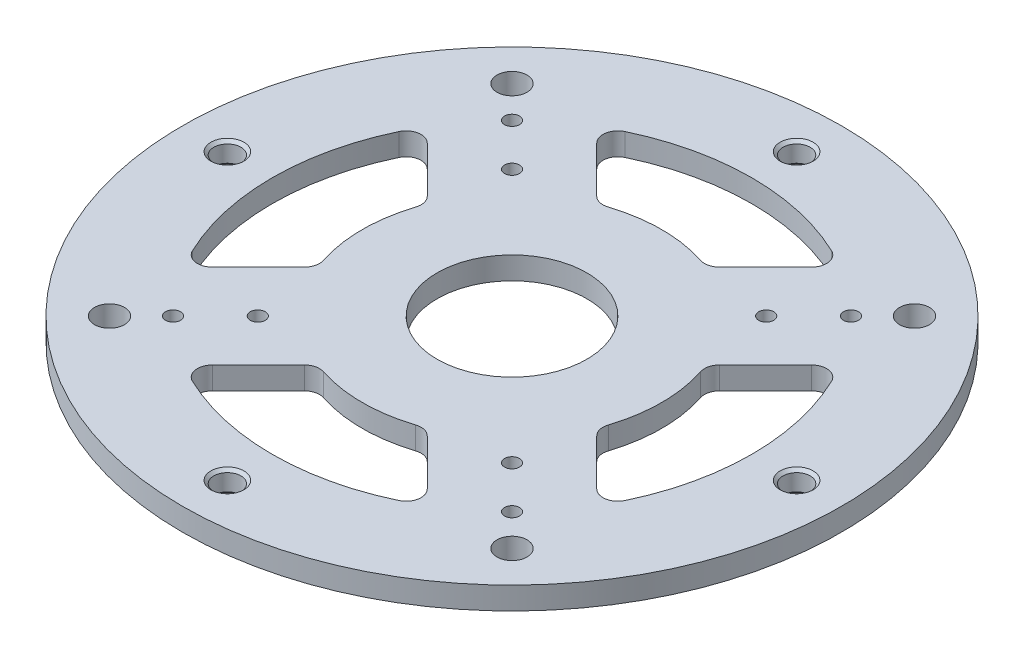
from build123d import *

# Parameters (mm, degrees)
SKETCH2_R                        = 139.7
SKETCH2_R_2                      = 31.75
BOSS_EXTRUDE1_DEPTH              = 9.525
SKETCH3_R                        = 3.175
SKETCH3_R_2                      = 6.35
CUT_EXTRUDE2_DEPTH               = 10.525
F_1_2_20_TAPPED_HOLE1_AT_2_COUNT = 2
F_1_2_20_TAPPED_HOLE1_AT_2_PITCH = 170.6248663
F_1_2_20_TAPPED_HOLE1_AT_3_COUNT = 2
F_1_2_20_TAPPED_HOLE1_AT_3_PITCH = 241.3
F_1_2_20_TAPPED_HOLE1_AT_4_COUNT = 2
F_1_2_20_TAPPED_HOLE1_AT_4_PITCH = 170.6248663


with BuildPart() as part:
    # Sketch2 → Boss-Extrude1 (new body)
    with BuildSketch(Plane(origin=(0, 0, 0), x_dir=(1, 0, 0), z_dir=(0, 1, 0))):
        Circle(SKETCH2_R)
        Circle(SKETCH2_R_2, mode=Mode.SUBTRACT)
        with BuildLine():
            Line((61.954602754, 26.03357827), (81.460512242, 45.539487758))
            ThreePointArc((81.460512242, 45.539487758), (87.024437868, 47.307910551), (91.68068299, 43.785983677))
            ThreePointArc((91.68068299, 43.785983677), (101.6, 0), (91.68068299, -43.785983677))
            ThreePointArc((91.68068299, -43.785983677), (87.024437868, -47.307910551), (81.460512242, -45.539487758))
            Line((81.460512242, -45.539487758), (61.954602754, -26.03357827))
            ThreePointArc((61.954602754, -26.03357827), (60.270643836, -23.027751383), (60.404300741, -19.584954736))
            ThreePointArc((60.404300741, -19.584954736), (63.5, 0), (60.404300741, 19.584954736))
            ThreePointArc((60.404300741, 19.584954736), (60.270643836, 23.027751383), (61.954602754, 26.03357827))
        make_face(mode=Mode.SUBTRACT)
        with BuildLine():
            Line((26.03357827, 61.954602754), (45.539487758, 81.460512242))
            ThreePointArc((45.539487758, 81.460512242), (47.307910551, 87.024437868), (43.785983677, 91.68068299))
            ThreePointArc((43.785983677, 91.68068299), (0, 101.6), (-43.785983677, 91.68068299))
            ThreePointArc((-43.785983677, 91.68068299), (-47.307910551, 87.024437868), (-45.539487758, 81.460512242))
            Line((-45.539487758, 81.460512242), (-26.03357827, 61.954602754))
            ThreePointArc((-26.03357827, 61.954602754), (-23.027751383, 60.270643836), (-19.584954736, 60.404300741))
            ThreePointArc((-19.584954736, 60.404300741), (0, 63.5), (19.584954736, 60.404300741))
            ThreePointArc((19.584954736, 60.404300741), (23.027751383, 60.270643836), (26.03357827, 61.954602754))
        make_face(mode=Mode.SUBTRACT)
        with BuildLine():
            Line((26.03357827, -61.954602754), (45.539487758, -81.460512242))
            ThreePointArc((45.539487758, -81.460512242), (47.307910551, -87.024437868), (43.785983677, -91.68068299))
            ThreePointArc((43.785983677, -91.68068299), (0, -101.6), (-43.785983677, -91.68068299))
            ThreePointArc((-43.785983677, -91.68068299), (-47.307910551, -87.024437868), (-45.539487758, -81.460512242))
            Line((-45.539487758, -81.460512242), (-26.03357827, -61.954602754))
            ThreePointArc((-26.03357827, -61.954602754), (-23.027751383, -60.270643836), (-19.584954736, -60.404300741))
            ThreePointArc((-19.584954736, -60.404300741), (0, -63.5), (19.584954736, -60.404300741))
            ThreePointArc((19.584954736, -60.404300741), (23.027751383, -60.270643836), (26.03357827, -61.954602754))
        make_face(mode=Mode.SUBTRACT)
        with BuildLine():
            Line((-61.954602754, -26.03357827), (-81.460512242, -45.539487758))
            ThreePointArc((-81.460512242, -45.539487758), (-87.024437868, -47.307910551), (-91.68068299, -43.785983677))
            ThreePointArc((-91.68068299, -43.785983677), (-101.6, 0), (-91.68068299, 43.785983677))
            ThreePointArc((-91.68068299, 43.785983677), (-87.024437868, 47.307910551), (-81.460512242, 45.539487758))
            Line((-81.460512242, 45.539487758), (-61.954602754, 26.03357827))
            ThreePointArc((-61.954602754, 26.03357827), (-60.270643836, 23.027751383), (-60.404300741, 19.584954736))
            ThreePointArc((-60.404300741, 19.584954736), (-63.5, 0), (-60.404300741, -19.584954736))
            ThreePointArc((-60.404300741, -19.584954736), (-60.270643836, -23.027751383), (-61.954602754, -26.03357827))
        make_face(mode=Mode.SUBTRACT)
    extrude(amount=BOSS_EXTRUDE1_DEPTH)

    # Sketch3 → Cut-Extrude2 (cut, through all)
    with BuildSketch(Plane(origin=(0, 9.525, 0), x_dir=(1, 0, 0), z_dir=(0, 1, 0))):
        with Locations((-71.842048969, 71.842048969)):
            Circle(SKETCH3_R)
        with Locations((-53.881536726, 53.881536726)):
            Circle(SKETCH3_R)
        with Locations((-71.842048969, -71.842048969)):
            Circle(SKETCH3_R)
        with Locations((71.842048969, -71.842048969)):
            Circle(SKETCH3_R)
        with Locations((71.842048969, 71.842048969)):
            Circle(SKETCH3_R)
        with Locations((53.881536726, 53.881536726)):
            Circle(SKETCH3_R)
        with Locations((53.881536726, -53.881536726)):
            Circle(SKETCH3_R)
        with Locations((-53.881536726, -53.881536726)):
            Circle(SKETCH3_R)
        with Locations((85.31243315, 85.31243315)):
            Circle(SKETCH3_R_2)
        with Locations((85.31243315, -85.31243315)):
            Circle(SKETCH3_R_2)
        with Locations((-85.31243315, -85.31243315)):
            Circle(SKETCH3_R_2)
        with Locations((-85.31243315, 85.31243315)):
            Circle(SKETCH3_R_2)
    extrude(amount=-CUT_EXTRUDE2_DEPTH, mode=Mode.SUBTRACT)

    # Sketch7 → 1/2-20 Tapped Hole1 (revolve, cut)
    with BuildSketch(Plane(origin=(-120.65, 9.525, 0), x_dir=(0, 0, 1), z_dir=(1, 0, 0))):
        Polygon((0, 0), (0, 9.525), (6.985, 9.525), (5.75437, 8.29437), (5.75437, 1.23063), (6.985, 0), align=None)
    f_1_2_20_tapped_hole1 = revolve(axis=Axis((-120.65, 15.875, 0), (0, -1, 0)), mode=Mode.SUBTRACT)

    # 1/2-20 Tapped Hole1 at 2: 1/2-20 Tapped Hole1 ×2
    with Locations(*[Vector(0.707106781, 0, -0.707106781) * (i * F_1_2_20_TAPPED_HOLE1_AT_2_PITCH) for i in range(1, F_1_2_20_TAPPED_HOLE1_AT_2_COUNT)]):
        add(f_1_2_20_tapped_hole1, mode=Mode.SUBTRACT)

    # 1/2-20 Tapped Hole1 at 3: 1/2-20 Tapped Hole1 ×2
    with Locations(*[(i * F_1_2_20_TAPPED_HOLE1_AT_3_PITCH, 0, 0) for i in range(1, F_1_2_20_TAPPED_HOLE1_AT_3_COUNT)]):
        add(f_1_2_20_tapped_hole1, mode=Mode.SUBTRACT)

    # 1/2-20 Tapped Hole1 at 4: 1/2-20 Tapped Hole1 ×2
    with Locations(*[Vector(0.707106781, 0, 0.707106781) * (i * F_1_2_20_TAPPED_HOLE1_AT_4_PITCH) for i in range(1, F_1_2_20_TAPPED_HOLE1_AT_4_COUNT)]):
        add(f_1_2_20_tapped_hole1, mode=Mode.SUBTRACT)


solid = part.part
